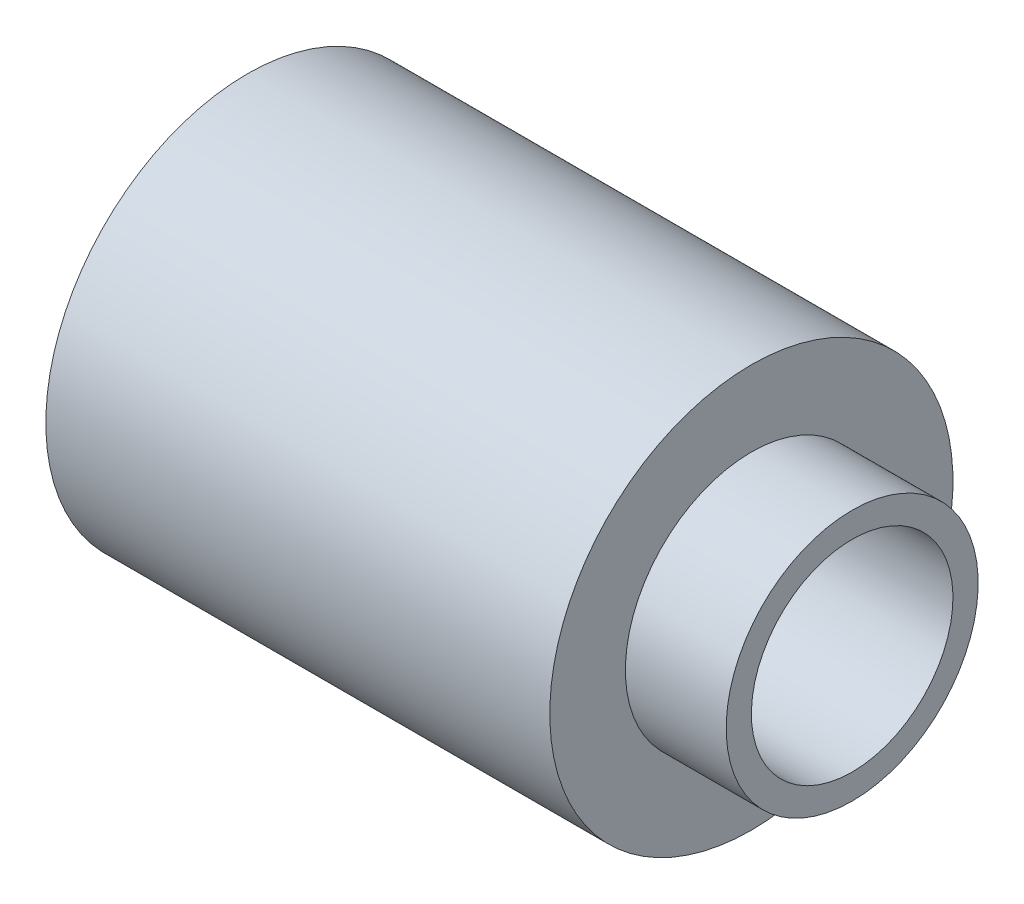
from build123d import *


with BuildPart() as part:
    # Sketch1 → Revolve1 (revolve)
    with BuildSketch(Plane.XY):
        Polygon((-4.376057876, 2), (-4.376057876, 4), (5.623942124, 4), (5.623942124, 2.5), (7.623942124, 2.5), (7.623942124, 2), align=None)
    revolve(axis=Axis((-6.194239694, 0, 0), (1, 0, 0)))


solid = part.part
